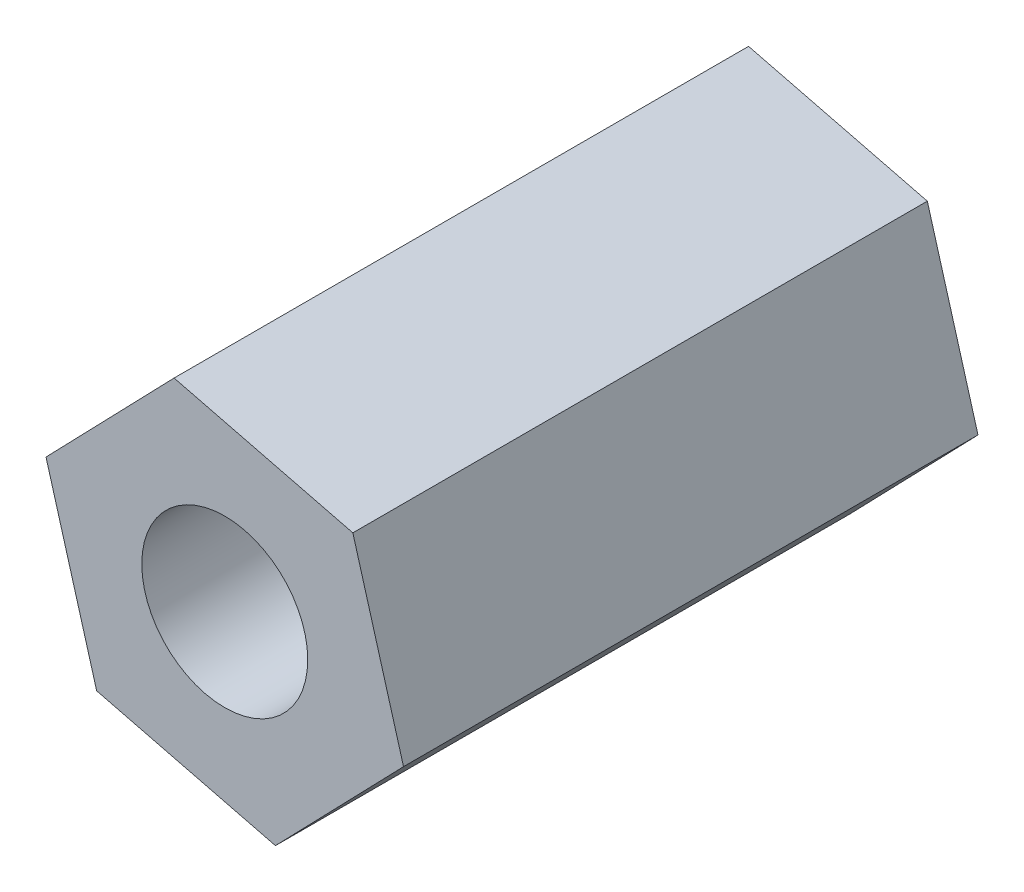
from build123d import *

# Parameters (mm, degrees)
BOSS_EXTRUDE1_DEPTH = 22.86
SKETCH2_R           = 3.302
CUT_EXTRUDE1_DEPTH  = 39.878


with BuildPart() as part:
    # Sketch1 → Boss-Extrude1 (new body)
    with BuildSketch(Plane.XY):
        Polygon((-7.113422827, 1.778355707), (-5.096812632, -5.271227023), (2.016610194, -7.049582729), (7.113422827, -1.778355707), (5.096812632, 5.271227023), (-2.016610194, 7.049582729), align=None)
    extrude(amount=BOSS_EXTRUDE1_DEPTH)

    # Sketch2 → Cut-Extrude1 (cut)
    with BuildSketch(Plane(origin=(0, 0, 0), x_dir=(-1, 0, 0), z_dir=(0, 0, -1))):
        Circle(SKETCH2_R)
    extrude(amount=-CUT_EXTRUDE1_DEPTH, mode=Mode.SUBTRACT)


solid = part.part
